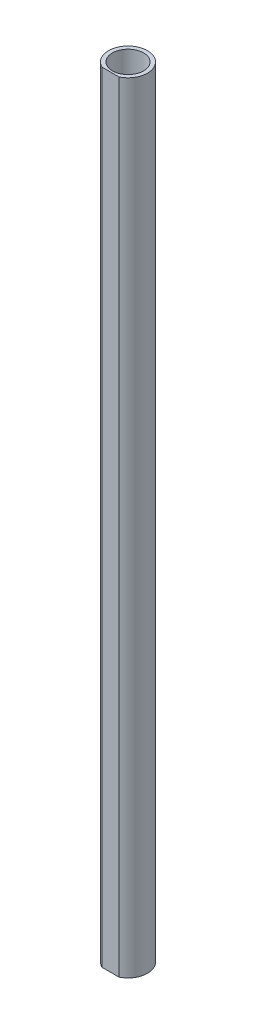
from build123d import *

# Parameters (mm, degrees)
SKETCH1_R               = 25
SKETCH1_R_2             = 20
BOSS_EXTRUDE1_DEPTH     = 1000
CUT_EXTRUDE1_DEPTH      = 1
CUT_EXTRUDE1_DEPTH_BACK = 1001


with BuildPart() as part:
    # Sketch1 → Boss-Extrude1 (new body)
    with BuildSketch(Plane(origin=(0, 0, 0), x_dir=(1, 0, 0), z_dir=(0, 1, 0))):
        Circle(SKETCH1_R)
        Circle(SKETCH1_R_2, mode=Mode.SUBTRACT)
    extrude(amount=BOSS_EXTRUDE1_DEPTH)

    # Sketch2 → Cut-Extrude1 (cut, two sides)
    with BuildSketch(Plane(origin=(0, 1000, 0), x_dir=(1, 0, 0), z_dir=(0, 1, 0))) as cut_extrude1_sk:
        Polygon((-139.974740916, -22.5), (-10.897247359, -22.5), (10.897247359, -22.5), (139.974740916, -22.5), (139.974740916, -280.654987114), (-139.974740916, -280.654987114), align=None)
    extrude(amount=CUT_EXTRUDE1_DEPTH, mode=Mode.SUBTRACT)
    extrude(cut_extrude1_sk.sketch, amount=-CUT_EXTRUDE1_DEPTH_BACK, mode=Mode.SUBTRACT)


solid = part.part
